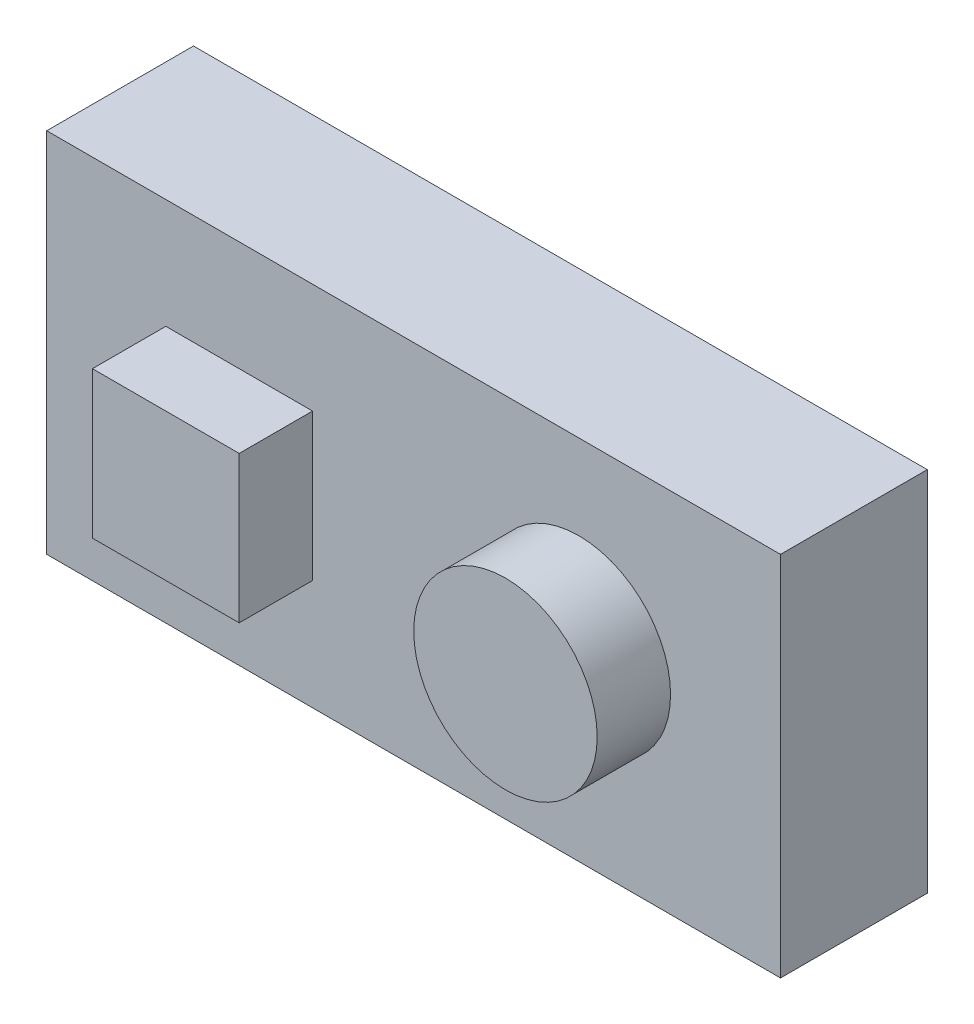
from build123d import *

# Parameters (mm, degrees)
SKETCH1_W           = 100
SKETCH1_H           = 50
BOSS_EXTRUDE1_DEPTH = 20
SKETCH2_R           = 12.5
SKETCH2_W           = 20
SKETCH2_H           = 20
BOSS_EXTRUDE2_DEPTH = 10


with BuildPart() as part:
    # Sketch1 → Boss-Extrude1 (new body)
    with BuildSketch(Plane.XY):
        with Locations((50, 25)):
            Rectangle(SKETCH1_W, SKETCH1_H)
    extrude(amount=BOSS_EXTRUDE1_DEPTH)

    # Sketch2 → Boss-Extrude2 (add)
    with BuildSketch(Plane.XY.offset(20)):
        with Locations((72.515853305, 25.964965142)):
            Circle(SKETCH2_R)
        with Locations((26.226220042, 25.028693536)):
            Rectangle(SKETCH2_W, SKETCH2_H)
    extrude(amount=BOSS_EXTRUDE2_DEPTH)


solid = part.part
